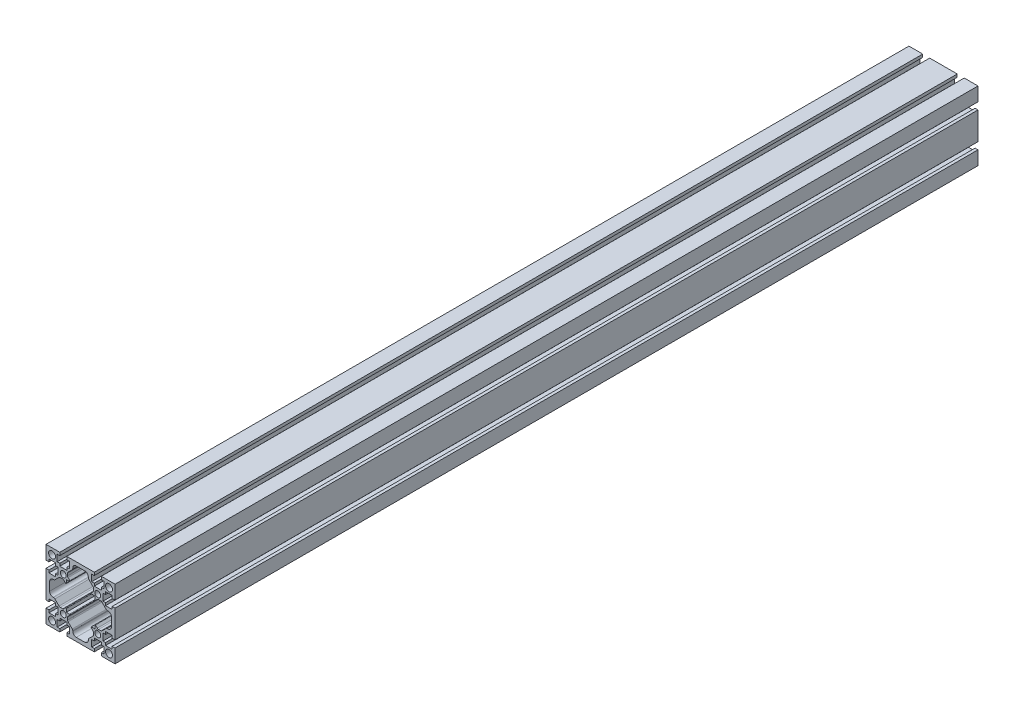
from build123d import *

# Parameters (mm, degrees)
SKETCH_1_R      = 4
SKETCH_1_R_2    = 3.4
EXTRUDE_1_DEPTH = 1000


with BuildPart() as part:
    # Эскиз1 → Бобышка-Вытянуть1 (new body)
    with BuildSketch(Plane.XY):
        Polygon((-40, 27.05), (-40, 40), (-27.05, 40), (-24.05, 40), (-24.05, 36.6), (-27.05, 36.6), (-27.05, 29), (-24.05, 29), (-24.05, 26), (-15.95, 26), (-15.95, 29), (-12.95, 29), (-12.95, 36.6), (-15.95, 36.6), (-15.95, 40), (-12.95, 40), (0, 40), (12.95, 40), (15.95, 40), (15.95, 36.6), (12.95, 36.6), (12.95, 29), (15.95, 29), (15.95, 26), (24.05, 26), (24.05, 29), (27.05, 29), (27.05, 36.6), (24.05, 36.6), (24.05, 40), (27.05, 40), (40, 40), (40, 27.05), (40, 24.05), (36.6, 24.05), (36.6, 27.05), (29, 27.05), (29, 24.05), (26, 24.05), (26, 15.95), (29, 15.95), (29, 12.95), (36.6, 12.95), (36.6, 15.95), (40, 15.95), (40, 12.95), (40, -12.95), (40, -15.95), (36.6, -15.95), (36.6, -12.95), (29, -12.95), (29, -15.95), (26, -15.95), (26, -24.05), (29, -24.05), (29, -27.05), (36.6, -27.05), (36.6, -24.05), (40, -24.05), (40, -27.05), (40, -40), (27.05, -40), (24.05, -40), (24.05, -36.6), (27.05, -36.6), (27.05, -29), (24.05, -29), (24.05, -26), (15.95, -26), (15.95, -29), (12.95, -29), (12.95, -36.6), (15.95, -36.6), (15.95, -40), (12.95, -40), (0, -40), (-12.95, -40), (-15.95, -40), (-15.95, -36.6), (-12.95, -36.6), (-12.95, -29), (-15.95, -29), (-15.95, -26), (-24.05, -26), (-24.05, -29), (-27.05, -29), (-27.05, -36.6), (-24.05, -36.6), (-24.05, -40), (-27.05, -40), (-40, -40), (-40, -27.05), (-40, -24.05), (-36.6, -24.05), (-36.6, -27.05), (-29, -27.05), (-29, -24.05), (-26, -24.05), (-26, -15.95), (-29, -15.95), (-29, -12.95), (-36.6, -12.95), (-36.6, -15.95), (-40, -15.95), (-40, -12.95), (-40, 12.95), (-40, 15.95), (-36.6, 15.95), (-36.6, 12.95), (-29, 12.95), (-29, 15.95), (-26, 15.95), (-26, 24.05), (-29, 24.05), (-29, 27.05), (-36.6, 27.05), (-36.6, 24.05), (-40, 24.05), align=None)
        with Locations((-33, 33)):
            Circle(SKETCH_1_R, mode=Mode.SUBTRACT)
        with Locations((-20, 20)):
            Circle(SKETCH_1_R_2, mode=Mode.SUBTRACT)
        with Locations((-20, -20)):
            Circle(SKETCH_1_R_2, mode=Mode.SUBTRACT)
        with Locations((-33, -33)):
            Circle(SKETCH_1_R, mode=Mode.SUBTRACT)
        with Locations((33, -33)):
            Circle(SKETCH_1_R, mode=Mode.SUBTRACT)
        with Locations((20, -20)):
            Circle(SKETCH_1_R_2, mode=Mode.SUBTRACT)
        with Locations((20, 20)):
            Circle(SKETCH_1_R_2, mode=Mode.SUBTRACT)
        with Locations((33, 33)):
            Circle(SKETCH_1_R, mode=Mode.SUBTRACT)
        with BuildLine():
            Line((-35.8, -5), (-35.8, 5))
            ThreePointArc((-35.8, 5), (-34.628427125, 7.828427125), (-31.8, 9))
            Line((-31.8, 9), (-31.128427125, 9))
            ThreePointArc((-31.128427125, 9), (-30.36306026, 9.152240935), (-29.714213562, 9.585786438))
            Line((-29.714213562, 9.585786438), (-24.885786438, 14.414213562))
            ThreePointArc((-24.885786438, 14.414213562), (-24.23693974, 14.847759065), (-23.471572875, 15))
            Line((-23.471572875, 15), (-20.828427125, 15))
            ThreePointArc((-20.828427125, 15), (-20.06306026, 14.847759065), (-19.414213562, 14.414213562))
            Line((-19.414213562, 14.414213562), (-17.353553391, 12.353553391))
            ThreePointArc((-17.353553391, 12.353553391), (-16.808658284, 12.245167015), (-16.5, 12.707106781))
            Line((-16.5, 12.707106781), (-16.5, 16.5))
            Line((-16.5, 16.5), (-12.707106781, 16.5))
            ThreePointArc((-12.707106781, 16.5), (-12.245167015, 16.808658284), (-12.353553391, 17.353553391))
            Line((-12.353553391, 17.353553391), (-14.414213562, 19.414213562))
            ThreePointArc((-14.414213562, 19.414213562), (-14.847759065, 20.06306026), (-15, 20.828427125))
            Line((-15, 20.828427125), (-15, 23.471572875))
            ThreePointArc((-15, 23.471572875), (-14.847759065, 24.23693974), (-14.414213562, 24.885786438))
            Line((-14.414213562, 24.885786438), (-9.585786438, 29.714213562))
            ThreePointArc((-9.585786438, 29.714213562), (-9.152240935, 30.36306026), (-9, 31.128427125))
            Line((-9, 31.128427125), (-9, 31.8))
            ThreePointArc((-9, 31.8), (-7.828427125, 34.628427125), (-5, 35.8))
            Line((-5, 35.8), (0, 35.8))
            Line((0, 35.8), (5, 35.8))
            ThreePointArc((5, 35.8), (7.828427125, 34.628427125), (9, 31.8))
            Line((9, 31.8), (9, 31.128427125))
            ThreePointArc((9, 31.128427125), (9.152240935, 30.36306026), (9.585786438, 29.714213562))
            Line((9.585786438, 29.714213562), (14.414213562, 24.885786438))
            ThreePointArc((14.414213562, 24.885786438), (14.847759065, 24.23693974), (15, 23.471572875))
            Line((15, 23.471572875), (15, 20.828427125))
            ThreePointArc((15, 20.828427125), (14.847759065, 20.06306026), (14.414213562, 19.414213562))
            Line((14.414213562, 19.414213562), (12.353553391, 17.353553391))
            ThreePointArc((12.353553391, 17.353553391), (12.245167015, 16.808658284), (12.707106781, 16.5))
            Line((12.707106781, 16.5), (16.5, 16.5))
            Line((16.5, 16.5), (16.5, 12.707106781))
            ThreePointArc((16.5, 12.707106781), (16.808658284, 12.245167015), (17.353553391, 12.353553391))
            Line((17.353553391, 12.353553391), (19.414213562, 14.414213562))
            ThreePointArc((19.414213562, 14.414213562), (20.06306026, 14.847759065), (20.828427125, 15))
            Line((20.828427125, 15), (23.471572875, 15))
            ThreePointArc((23.471572875, 15), (24.23693974, 14.847759065), (24.885786438, 14.414213562))
            Line((24.885786438, 14.414213562), (29.714213562, 9.585786438))
            ThreePointArc((29.714213562, 9.585786438), (30.36306026, 9.152240935), (31.128427125, 9))
            Line((31.128427125, 9), (31.8, 9))
            ThreePointArc((31.8, 9), (34.628427125, 7.828427125), (35.8, 5))
            Line((35.8, 5), (35.8, -5))
            ThreePointArc((35.8, -5), (34.628427125, -7.828427125), (31.8, -9))
            Line((31.8, -9), (31.128427125, -9))
            ThreePointArc((31.128427125, -9), (30.36306026, -9.152240935), (29.714213562, -9.585786438))
            Line((29.714213562, -9.585786438), (24.885786438, -14.414213562))
            ThreePointArc((24.885786438, -14.414213562), (24.23693974, -14.847759065), (23.471572875, -15))
            Line((23.471572875, -15), (20.828427125, -15))
            ThreePointArc((20.828427125, -15), (20.06306026, -14.847759065), (19.414213562, -14.414213562))
            Line((19.414213562, -14.414213562), (17.353553391, -12.353553391))
            ThreePointArc((17.353553391, -12.353553391), (16.808658284, -12.245167015), (16.5, -12.707106781))
            Line((16.5, -12.707106781), (16.5, -16.5))
            Line((16.5, -16.5), (12.707106781, -16.5))
            ThreePointArc((12.707106781, -16.5), (12.245167015, -16.808658284), (12.353553391, -17.353553391))
            Line((12.353553391, -17.353553391), (14.414213562, -19.414213562))
            ThreePointArc((14.414213562, -19.414213562), (14.847759065, -20.06306026), (15, -20.828427125))
            Line((15, -20.828427125), (15, -23.471572875))
            ThreePointArc((15, -23.471572875), (14.847759065, -24.23693974), (14.414213562, -24.885786438))
            Line((14.414213562, -24.885786438), (9.585786438, -29.714213562))
            ThreePointArc((9.585786438, -29.714213562), (9.152240935, -30.36306026), (9, -31.128427125))
            Line((9, -31.128427125), (9, -31.8))
            ThreePointArc((9, -31.8), (7.828427125, -34.628427125), (5, -35.8))
            Line((5, -35.8), (0, -35.8))
            Line((0, -35.8), (-5, -35.8))
            ThreePointArc((-5, -35.8), (-7.828427125, -34.628427125), (-9, -31.8))
            Line((-9, -31.8), (-9, -31.128427125))
            ThreePointArc((-9, -31.128427125), (-9.152240935, -30.36306026), (-9.585786438, -29.714213562))
            Line((-9.585786438, -29.714213562), (-14.414213562, -24.885786438))
            ThreePointArc((-14.414213562, -24.885786438), (-14.847759065, -24.23693974), (-15, -23.471572875))
            Line((-15, -23.471572875), (-15, -20.828427125))
            ThreePointArc((-15, -20.828427125), (-14.847759065, -20.06306026), (-14.414213562, -19.414213562))
            Line((-14.414213562, -19.414213562), (-12.353553391, -17.353553391))
            ThreePointArc((-12.353553391, -17.353553391), (-12.245167015, -16.808658284), (-12.707106781, -16.5))
            Line((-12.707106781, -16.5), (-16.5, -16.5))
            Line((-16.5, -16.5), (-16.5, -12.707106781))
            ThreePointArc((-16.5, -12.707106781), (-16.808658284, -12.245167015), (-17.353553391, -12.353553391))
            Line((-17.353553391, -12.353553391), (-19.414213562, -14.414213562))
            ThreePointArc((-19.414213562, -14.414213562), (-20.06306026, -14.847759065), (-20.828427125, -15))
            Line((-20.828427125, -15), (-23.471572875, -15))
            ThreePointArc((-23.471572875, -15), (-24.23693974, -14.847759065), (-24.885786438, -14.414213562))
            Line((-24.885786438, -14.414213562), (-29.714213562, -9.585786438))
            ThreePointArc((-29.714213562, -9.585786438), (-30.36306026, -9.152240935), (-31.128427125, -9))
            Line((-31.128427125, -9), (-31.8, -9))
            ThreePointArc((-31.8, -9), (-34.628427125, -7.828427125), (-35.8, -5))
        make_face(mode=Mode.SUBTRACT)
    extrude(amount=EXTRUDE_1_DEPTH)


solid = part.part
